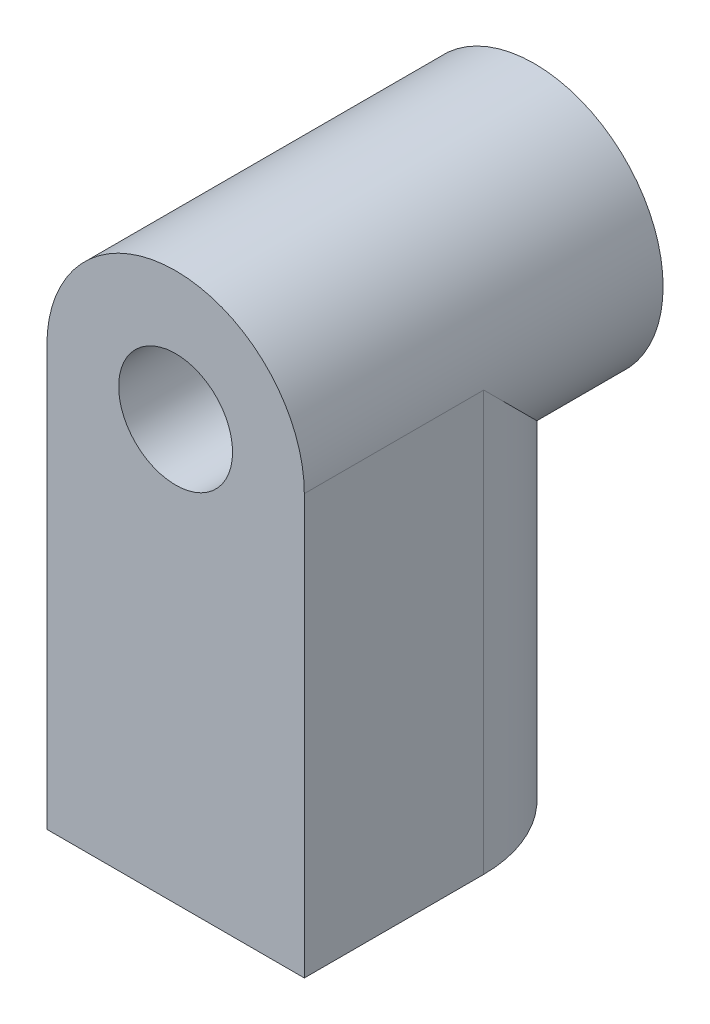
from build123d import *

# Parameters (mm, degrees)
SKETCH1_R           = 3.5875
SKETCH1_R_2         = 1.5875
BOSS_EXTRUDE1_DEPTH = 10
SKETCH2_R           = 1.5875
BOSS_EXTRUDE2_DEPTH = 10
BOSS_EXTRUDE3_REACH = 7.279


with BuildPart() as part:
    # Sketch1 → Boss-Extrude1 (new body)
    with BuildSketch(Plane.XY):
        Circle(SKETCH1_R)
        Circle(SKETCH1_R_2, mode=Mode.SUBTRACT)
    extrude(amount=BOSS_EXTRUDE1_DEPTH)

    # Sketch2 → Boss-Extrude2 (add)
    with BuildSketch(Plane(origin=(0, -1.69195383, 0), x_dir=(1, 0, 0), z_dir=(0, 1, 0))):
        with BuildLine():
            Line((-3.5875, -5), (-3.5875, -10))
            Line((-3.5875, -10), (3.5875, -10))
            Line((3.5875, -10), (3.5875, -5))
            ThreePointArc((3.5875, -5), (0, -1.4125), (-3.5875, -5))
        make_face()
        with Locations((0, -5)):
            Circle(SKETCH2_R, mode=Mode.SUBTRACT)
    extrude(amount=-BOSS_EXTRUDE2_DEPTH)

    # Sketch3 → Boss-Extrude3 (add, up to next)
    with BuildSketch(Plane(origin=(0, -1.69195383, 0), x_dir=(1, 0, 0), z_dir=(0, 1, 0)), mode=Mode.PRIVATE) as boss_extrude3_sk1:
        with BuildLine():
            Line((-3.5875, -10), (-3.5875, -5))
            ThreePointArc((-3.5875, -5), (-3.479874394, -4.127858699), (-3.16345515, -3.30804617))
            Line((-3.16345515, -3.30804617), (-3.16345515, -10))
            Line((-3.16345515, -10), (-3.5875, -10))
        make_face()
    boss_extrude3_tool1 = extrude(boss_extrude3_sk1.sketch, amount=BOSS_EXTRUDE3_REACH, mode=Mode.PRIVATE) - part.part
    add(boss_extrude3_tool1.solids().sort_by_distance((-3.367759, -1.691954, 6.916202))[0])
    # Sketch3 → Boss-Extrude3 (add, up to next)
    with BuildSketch(Plane(origin=(0, -1.69195383, 0), x_dir=(1, 0, 0), z_dir=(0, 1, 0)), mode=Mode.PRIVATE) as boss_extrude3_sk2:
        with BuildLine():
            Line((3.16345515, -10), (3.16345515, -3.30804617))
            ThreePointArc((3.16345515, -3.30804617), (3.479874394, -4.127858699), (3.5875, -5))
            Line((3.5875, -5), (3.5875, -10))
            Line((3.5875, -10), (3.16345515, -10))
        make_face()
    boss_extrude3_tool2 = extrude(boss_extrude3_sk2.sketch, amount=BOSS_EXTRUDE3_REACH, mode=Mode.PRIVATE) - part.part
    add(boss_extrude3_tool2.solids().sort_by_distance((3.367759, -1.691954, 6.916202))[0])


solid = part.part
